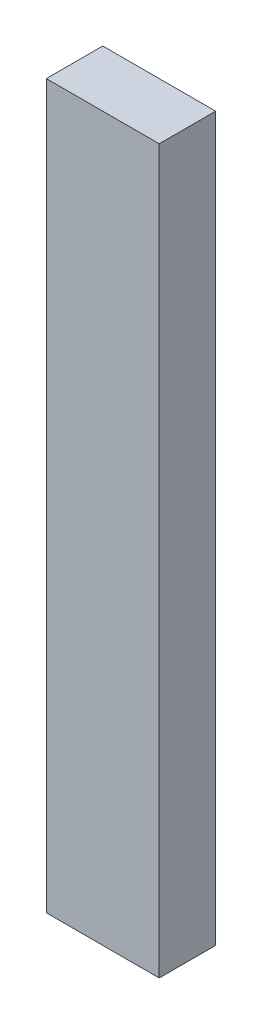
from build123d import *

# Parameters (mm, degrees)
SKETCH1_W           = 0.5
SKETCH1_H           = 0.25
BOSS_EXTRUDE1_DEPTH = 3.2


with BuildPart() as part:
    # Sketch1 → Boss-Extrude1 (new body)
    with BuildSketch(Plane(origin=(0, 0, 0), x_dir=(1, 0, 0), z_dir=(0, 1, 0))):
        Rectangle(SKETCH1_W, SKETCH1_H)
    extrude(amount=BOSS_EXTRUDE1_DEPTH)


solid = part.part
